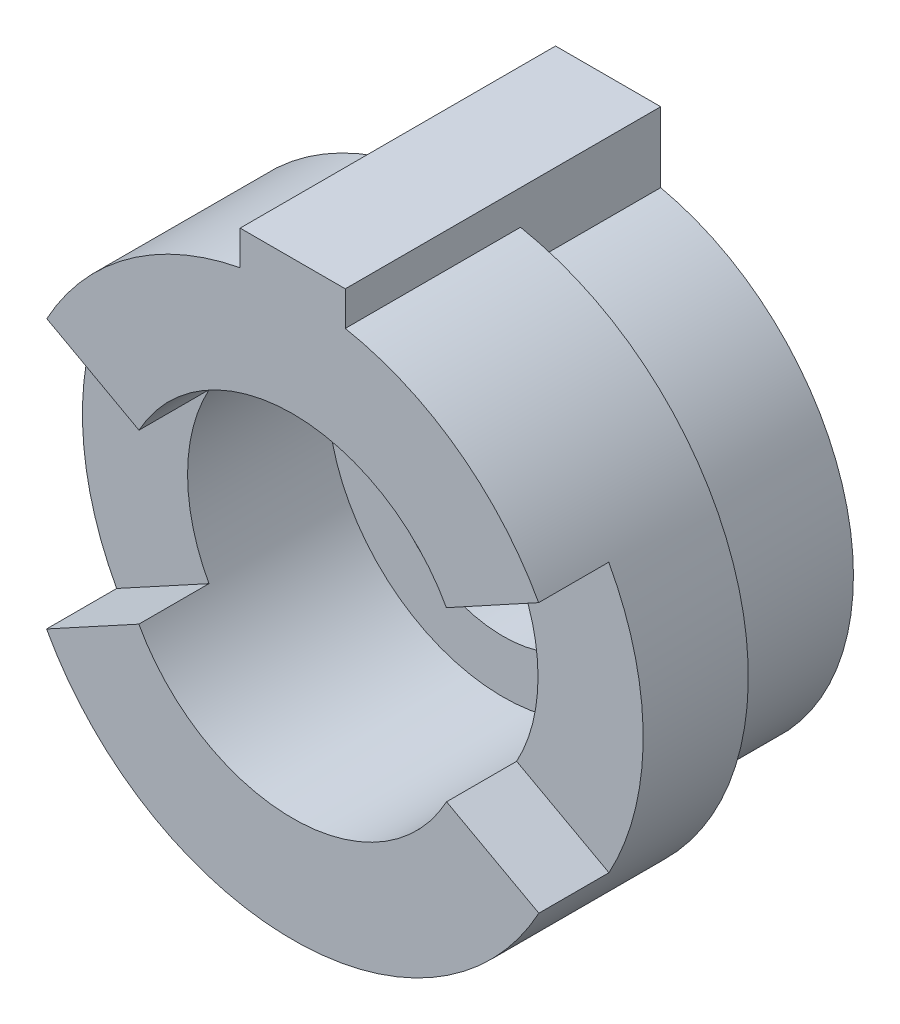
from build123d import *

# Parameters (mm, degrees)
SKETCH1_R                = 8
SKETCH1_R_2              = 3.5
BOSS_EXTRUDE1_DEPTH      = 3
SKETCH2_R                = 8
SKETCH2_R_2              = 5
BOSS_EXTRUDE2_DEPTH      = 6
WRAP3_SECTION_W          = 4
WRAP3_SECTION_H          = 2
WRAP3_ANGLE              = 57.295779513
WRAP3_SECTOR_2_SECTION_W = 4
WRAP3_SECTOR_2_SECTION_H = 2
WRAP3_SECTOR_2_ANGLE     = 57.295779513
CUT_EXTRUDE1_DEPTH       = 4
BOSS_EXTRUDE3_DEPTH      = 9


with BuildPart() as part:
    # Sketch1 → Boss-Extrude1 (new body)
    with BuildSketch(Plane.XY):
        Circle(SKETCH1_R)
        Circle(SKETCH1_R_2, mode=Mode.SUBTRACT)
    extrude(amount=BOSS_EXTRUDE1_DEPTH)

    # Sketch2 → Boss-Extrude2 (add)
    with BuildSketch(Plane.XY.offset(3)):
        Circle(SKETCH2_R)
        Circle(SKETCH2_R_2, mode=Mode.SUBTRACT)
    extrude(amount=BOSS_EXTRUDE2_DEPTH)

    # Wrap3 section (on wrap section) → Wrap3 (revolve, cut)
    with BuildSketch(Plane(origin=(0, 0, 0), x_dir=(-0.8779640629990781, -0.4787265441587198, 0), z_dir=(0.4787265441587198, -0.8779640629990781, 0))):
        with Locations((6, -8)):
            Rectangle(WRAP3_SECTION_W, WRAP3_SECTION_H)
    revolve(axis=Axis((0, 0, 0), (0, 0, -1)), revolution_arc=WRAP3_ANGLE, mode=Mode.SUBTRACT)

    # Wrap3 sector 2 section (on wrap section) → Wrap3 sector 2 (revolve, cut)
    with BuildSketch(Plane(origin=(0, 0, 0), x_dir=(0.8772005042746819, 0.4801242290285337, 0), z_dir=(-0.4801242290285337, 0.8772005042746819, 0))):
        with Locations((6, -8)):
            Rectangle(WRAP3_SECTOR_2_SECTION_W, WRAP3_SECTOR_2_SECTION_H)
    revolve(axis=Axis((0, 0, 0), (0, 0, -1)), revolution_arc=WRAP3_SECTOR_2_ANGLE, mode=Mode.SUBTRACT)

    # Sketch5 → Cut-Extrude1 (cut)
    with BuildSketch(Plane(origin=(0, 0, 0), x_dir=(-1, 0, 0), z_dir=(0, 0, -1))):
        with BuildLine():
            Line((-1.5, 6.837397166), (-1.5, 7.858116823))
            ThreePointArc((-1.5, 7.858116823), (0, -8), (1.5, 7.858116823))
            Line((1.5, 7.858116823), (1.5, 6.837397166))
            ThreePointArc((1.5, 6.837397166), (0, -7), (-1.5, 6.837397166))
        make_face()
    extrude(amount=-CUT_EXTRUDE1_DEPTH, mode=Mode.SUBTRACT)

    # Sketch6 → Boss-Extrude3 (add)
    with BuildSketch(Plane(origin=(0, 0, 0), x_dir=(-1, 0, 0), z_dir=(0, 0, -1))):
        with BuildLine():
            Line((-1.5, 7.858116823), (-1.5, 8.837397166))
            Line((-1.5, 8.837397166), (1.5, 8.837397166))
            Line((1.5, 8.837397166), (1.5, 7.858116823))
            ThreePointArc((1.5, 7.858116823), (0, 8), (-1.5, 7.858116823))
        make_face()
    extrude(amount=-BOSS_EXTRUDE3_DEPTH)


solid = part.part
